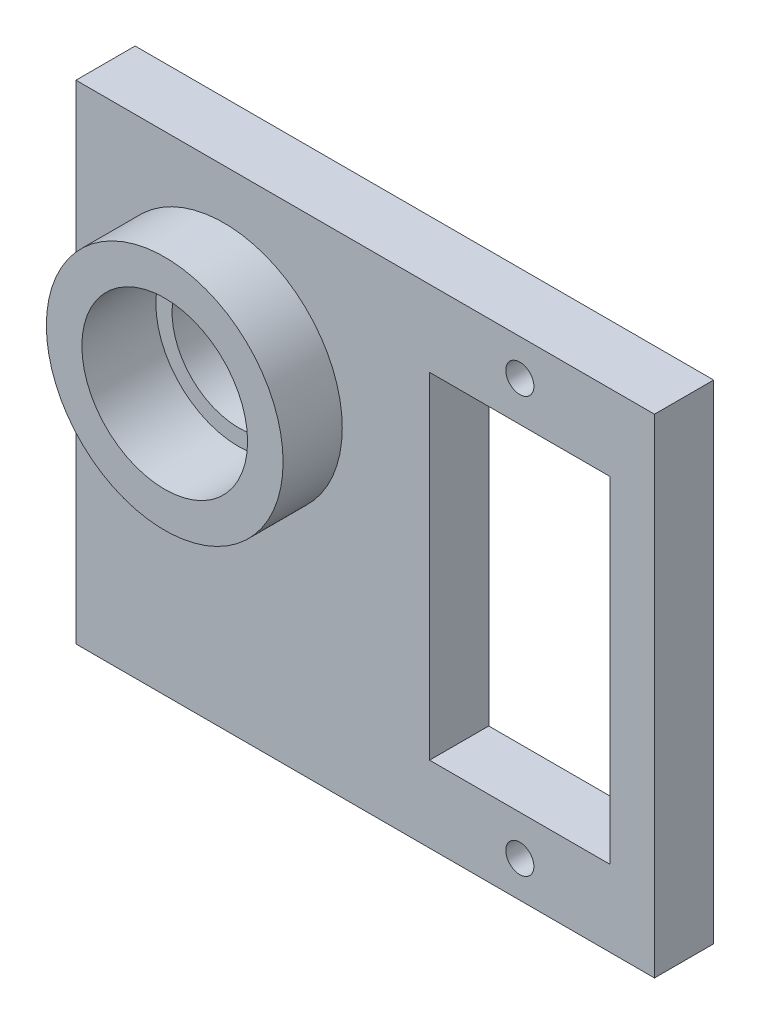
from build123d import *

# Parameters (mm, degrees)
SKETCH1_W           = 39.1
SKETCH1_H           = 33
SKETCH1_R           = 0.95
SKETCH1_R_2         = 4.5
SKETCH1_W_2         = 12.2
SKETCH1_H_2         = 22.7
BOSS_EXTRUDE1_DEPTH = 4
BOSS_EXTRUDE2_START = 4
SKETCH2_R           = 8
SKETCH2_R_2         = 4.403773093
BOSS_EXTRUDE2_DEPTH = 4
CUT_EXTRUDE1_START  = 8
SKETCH3_R           = 5.6
CUT_EXTRUDE1_DEPTH  = 5


with BuildPart() as part:
    # Sketch1 → Boss-Extrude1 (new body)
    with BuildSketch(Plane.XY):
        with Locations((-10.45, -5.15)):
            Rectangle(SKETCH1_W, SKETCH1_H)
        with Locations((0, 8.9)):
            Circle(SKETCH1_R, mode=Mode.SUBTRACT)
        with Locations((0, -19.2)):
            Circle(SKETCH1_R, mode=Mode.SUBTRACT)
        with Locations((-20, 0)):
            Circle(SKETCH1_R_2, mode=Mode.SUBTRACT)
        with Locations((0, -5.15)):
            Rectangle(SKETCH1_W_2, SKETCH1_H_2, mode=Mode.SUBTRACT)
    extrude(amount=BOSS_EXTRUDE1_DEPTH)

    # Sketch2 → Boss-Extrude2 (add)
    with BuildSketch(Plane.XY.offset(BOSS_EXTRUDE2_START)):
        with Locations((-20, 0)):
            Circle(SKETCH2_R)
        with Locations((-20, 0)):
            Circle(SKETCH2_R_2, mode=Mode.SUBTRACT)
    extrude(amount=BOSS_EXTRUDE2_DEPTH)

    # Sketch3 → Cut-Extrude1 (cut)
    with BuildSketch(Plane.XY.offset(CUT_EXTRUDE1_START)):
        with Locations((-20, 0)):
            Circle(SKETCH3_R)
    extrude(amount=-CUT_EXTRUDE1_DEPTH, mode=Mode.SUBTRACT)


solid = part.part
